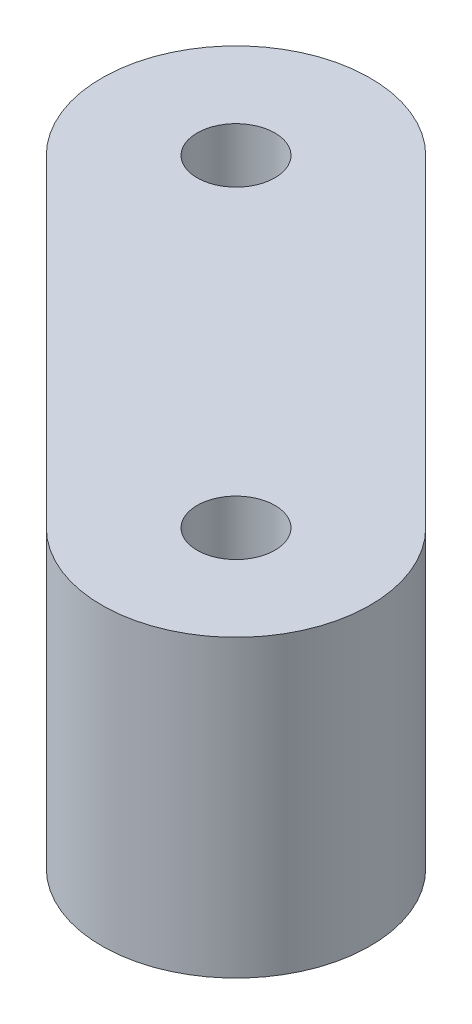
from build123d import *

# Parameters (mm, degrees)
SALIENTE_EXTRUIR1_DEPTH = 11
CROQUIS2_R              = 1.45
CORTAR_EXTRUIR1_DEPTH   = 11
CORTAR_EXTRUIR2_DEPTH   = 7


with BuildPart() as part:
    # Croquis1 → Saliente-Extruir1 (new body)
    with BuildSketch(Plane(origin=(0, -33.400588291, 0), x_dir=(1, 0, 0), z_dir=(0, 1, 0))):
        with BuildLine():
            Line((-45.256444502, -97.372583002), (-33.235629222, -109.393398282))
            ThreePointArc((-33.235629222, -109.393398282), (-26.16456141, -109.393398282), (-26.16456141, -102.32233047))
            Line((-26.16456141, -102.32233047), (-38.18537669, -90.30151519))
            ThreePointArc((-38.18537669, -90.30151519), (-45.256444502, -90.30151519), (-45.256444502, -97.372583002))
        make_face()
    extrude(amount=SALIENTE_EXTRUIR1_DEPTH)

    # Croquis2 → Cortar-Extruir1 (cut)
    with BuildSketch(Plane.XZ.offset(33.400588291)):
        with Locations((-41.720910596, 93.837049096)):
            Circle(CROQUIS2_R)
        with Locations((-29.700095316, 105.857864376)):
            Circle(CROQUIS2_R)
    extrude(amount=-CORTAR_EXTRUIR1_DEPTH, mode=Mode.SUBTRACT)

    # Croquis3 → Cortar-Extruir2 (cut)
    with BuildSketch(Plane.XZ.offset(33.400588291)):
        Polygon((-40.24952431, 104.38647809), (-37.421097185, 107.214905215), (-26.82292811, 96.61673614), (-32.47978236, 90.95988189), (-43.077951435, 101.558050965), align=None)
    extrude(amount=-CORTAR_EXTRUIR2_DEPTH, mode=Mode.SUBTRACT)


solid = part.part
